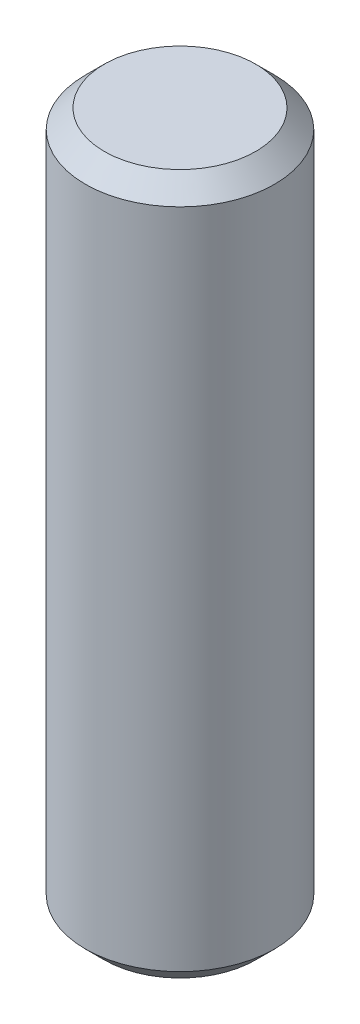
from build123d import *

# Parameters (mm, degrees)
SKETCH1_R           = 10
BOSS_EXTRUDE1_DEPTH = 37
CHAMFER1_SIZE       = 2


with BuildPart() as part:
    # Sketch1 → Boss-Extrude1 (new body, symmetric)
    with BuildSketch(Plane(origin=(0, 0, 0), x_dir=(1, 0, 0), z_dir=(0, 1, 0))):
        Circle(SKETCH1_R)
    extrude(amount=BOSS_EXTRUDE1_DEPTH, both=True)

    # Chamfer1
    chamfer1_edges = [part.edges().sort_by_distance(p)[0] for p in [
        (-10, -37, 0),
        (-10, 37, 0),
    ]]
    chamfer(chamfer1_edges, length=CHAMFER1_SIZE)


solid = part.part
